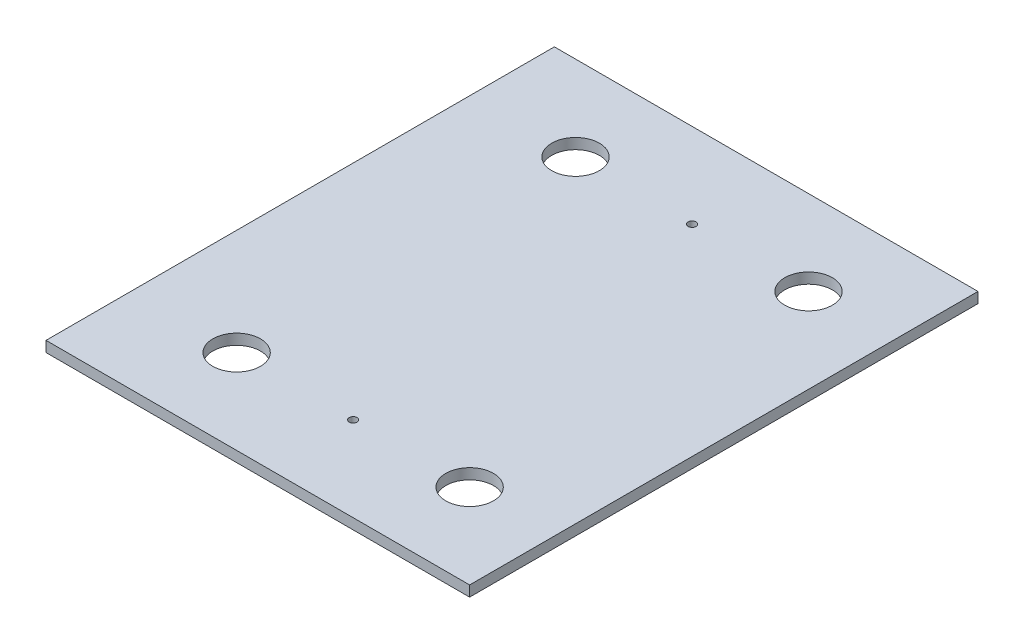
from build123d import *

# Parameters (mm, degrees)
SKETCH1_W           = 254
SKETCH1_H           = 304.8
SKETCH1_R           = 14.2875
SKETCH1_R_2         = 2.38125
BOSS_EXTRUDE1_DEPTH = 6.35


with BuildPart() as part:
    # Sketch1 → Boss-Extrude1 (new body)
    with BuildSketch(Plane(origin=(0, 0, 0), x_dir=(1, 0, 0), z_dir=(0, 1, 0))):
        with Locations((127, 152.4)):
            Rectangle(SKETCH1_W, SKETCH1_H)
        with Locations((63.5, 50.8)):
            Circle(SKETCH1_R, mode=Mode.SUBTRACT)
        with Locations((203.2, 50.8)):
            Circle(SKETCH1_R, mode=Mode.SUBTRACT)
        with Locations((63.5, 254)):
            Circle(SKETCH1_R, mode=Mode.SUBTRACT)
        with Locations((203.2, 254)):
            Circle(SKETCH1_R, mode=Mode.SUBTRACT)
        with Locations((133.35, 254)):
            Circle(SKETCH1_R_2, mode=Mode.SUBTRACT)
        with Locations((133.35, 50.8)):
            Circle(SKETCH1_R_2, mode=Mode.SUBTRACT)
    extrude(amount=BOSS_EXTRUDE1_DEPTH)


solid = part.part
